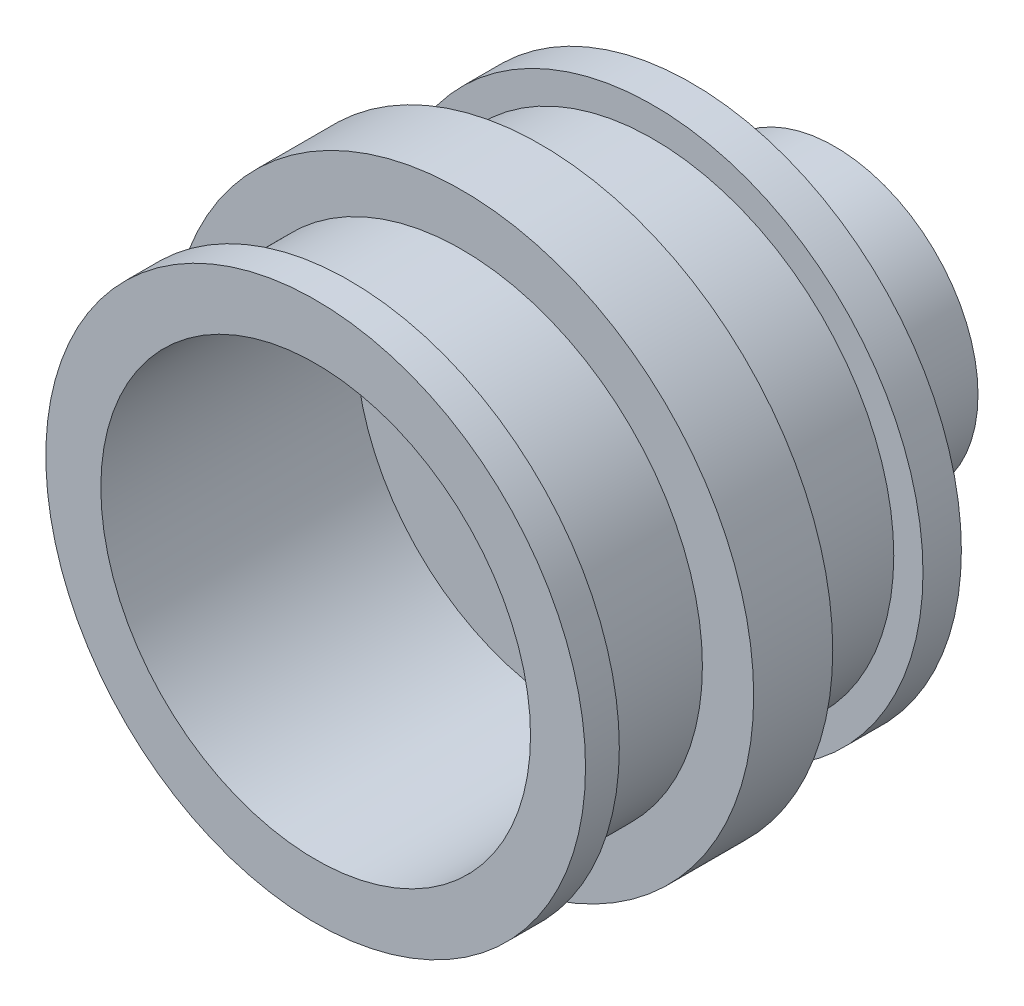
from build123d import *

# Parameters (mm, degrees)
SZKIC1_R                    = 9.42
DODANIE_WYCI_GNI_CIE1_DEPTH = 1.34
SZKIC2_R                    = 8.4
DODANIE_WYCI_GNI_CIE2_DEPTH = 3.92
SZKIC3_R                    = 10.19
DODANIE_WYCI_GNI_CIE3_DEPTH = 2.76
SZKIC4_R                    = 8.4
DODANIE_WYCI_GNI_CIE4_DEPTH = 3.92
SZKIC5_R                    = 9.42
DODANIE_WYCI_GNI_CIE5_DEPTH = 1.18
SZKIC6_R                    = 7.5
WYTNIJ_WYCI_GNI_CIE1_DEPTH  = 8.9
WYTNIJ_WYCI_GNI_CIE2_REACH  = 15.12
SZKIC7_R                    = 1.5
CROQUIS1_R                  = 5
CROQUIS1_R_2                = 1.5
SALIENTE_EXTRUIR1_DEPTH     = 5
CROQUIS2_R                  = 0.635
CORTAR_EXTRUIR1_DEPTH       = 11.19
CORTAR_EXTRUIR1_DEPTH_BACK  = 11.19


with BuildPart() as part:
    # Szkic1 → Dodanie-wyciągnięcie1 (new body)
    with BuildSketch(Plane.XY):
        Circle(SZKIC1_R)
    extrude(amount=DODANIE_WYCI_GNI_CIE1_DEPTH)

    # Szkic2 → Dodanie-wyciągnięcie2 (add)
    with BuildSketch(Plane.XY.offset(1.34)):
        Circle(SZKIC2_R)
    extrude(amount=DODANIE_WYCI_GNI_CIE2_DEPTH)

    # Szkic3 → Dodanie-wyciągnięcie3 (add)
    with BuildSketch(Plane.XY.offset(5.26)):
        Circle(SZKIC3_R)
    extrude(amount=DODANIE_WYCI_GNI_CIE3_DEPTH)

    # Szkic4 → Dodanie-wyciągnięcie4 (add)
    with BuildSketch(Plane.XY.offset(8.02)):
        Circle(SZKIC4_R)
    extrude(amount=DODANIE_WYCI_GNI_CIE4_DEPTH)

    # Szkic5 → Dodanie-wyciągnięcie5 (add)
    with BuildSketch(Plane.XY.offset(11.94)):
        Circle(SZKIC5_R)
    extrude(amount=DODANIE_WYCI_GNI_CIE5_DEPTH)

    # Szkic6 → Wytnij-wyciągnięcie1 (cut)
    with BuildSketch(Plane.XY.offset(13.12)):
        Circle(SZKIC6_R)
    extrude(amount=-WYTNIJ_WYCI_GNI_CIE1_DEPTH, mode=Mode.SUBTRACT)

    # Szkic7 → Wytnij-wyciągnięcie2 (cut, up to next)
    with BuildSketch(Plane(origin=(0, 0, 0), x_dir=(-1, 0, 0), z_dir=(0, 0, -1)), mode=Mode.PRIVATE) as wytnij_wyci_gni_cie2_sk1:
        Circle(SZKIC7_R)
    wytnij_wyci_gni_cie2_tool1 = extrude(wytnij_wyci_gni_cie2_sk1.sketch, amount=-WYTNIJ_WYCI_GNI_CIE2_REACH, mode=Mode.PRIVATE) & part.part
    add(wytnij_wyci_gni_cie2_tool1.solids().sort_by_distance((0, 0, 0))[0], mode=Mode.SUBTRACT)

    # Croquis1 → Saliente-Extruir1 (add)
    with BuildSketch(Plane(origin=(0, 0, 0), x_dir=(-1, 0, 0), z_dir=(0, 0, -1))):
        Circle(CROQUIS1_R)
        Circle(CROQUIS1_R_2, mode=Mode.SUBTRACT)
    extrude(amount=SALIENTE_EXTRUIR1_DEPTH)

    # Croquis2 → Cortar-Extruir1 (cut, two sides)
    with BuildSketch(Plane(origin=(0, 0, 0), x_dir=(1, 0, 0), z_dir=(0, 1, 0))) as cortar_extruir1_sk:
        with Locations((0, 2.367182901)):
            Circle(CROQUIS2_R)
    extrude(amount=CORTAR_EXTRUIR1_DEPTH, mode=Mode.SUBTRACT)
    extrude(cortar_extruir1_sk.sketch, amount=-CORTAR_EXTRUIR1_DEPTH_BACK, mode=Mode.SUBTRACT)


solid = part.part
